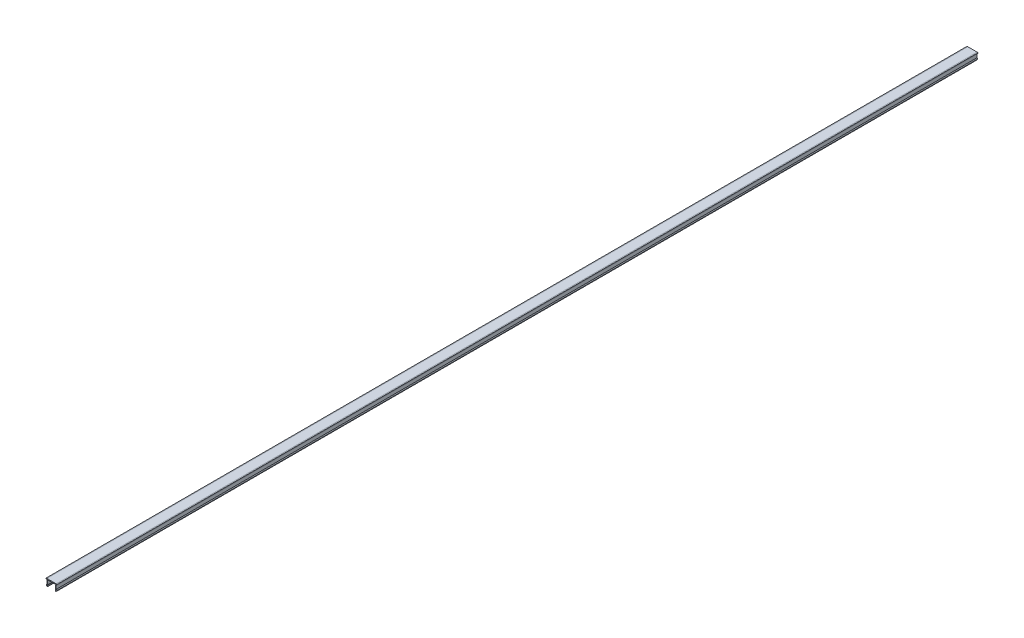
from build123d import *

# Parameters (mm, degrees)
EXTRUDE_1_DEPTH = 1000


with BuildPart() as part:
    # Эскиз1 → Бобышка-Вытянуть1 (new body)
    with BuildSketch(Plane.XY):
        with BuildLine():
            Line((-5.1, 0), (-6, -0.158694283))
            Line((-6, -0.158694283), (-6, -0.8))
            Line((-6, -0.8), (-5.1, -0.8))
            Line((-5.1, -0.8), (-5.1, -5.196152423))
            Line((-5.1, -5.196152423), (-5.68771324, -6.214101615))
            Line((-5.68771324, -6.214101615), (-5.1, -7.232050808))
            ThreePointArc((-5.1, -7.232050808), (-4.497197677, -7.481739705), (-4.1, -6.964101615))
            Line((-4.1, -6.964101615), (-4.533012702, -6.214101615))
            Line((-4.533012702, -6.214101615), (-4.1, -5.464101615))
            Line((-4.1, -5.464101615), (-4.1, -1))
            Line((-4.1, -1), (4.1, -1))
            Line((4.1, -1), (4.1, -5.464101615))
            Line((4.1, -5.464101615), (4.533012702, -6.214101615))
            Line((4.533012702, -6.214101615), (4.1, -6.964101615))
            ThreePointArc((4.1, -6.964101615), (4.497197677, -7.481739705), (5.1, -7.232050808))
            Line((5.1, -7.232050808), (5.68771324, -6.214101615))
            Line((5.68771324, -6.214101615), (5.1, -5.196152423))
            Line((5.1, -5.196152423), (5.1, -0.8))
            Line((5.1, -0.8), (6, -0.8))
            Line((6, -0.8), (6, -0.158694283))
            Line((6, -0.158694283), (5.1, 0))
            Line((5.1, 0), (-5.1, 0))
        make_face()
    extrude(amount=EXTRUDE_1_DEPTH)


solid = part.part
